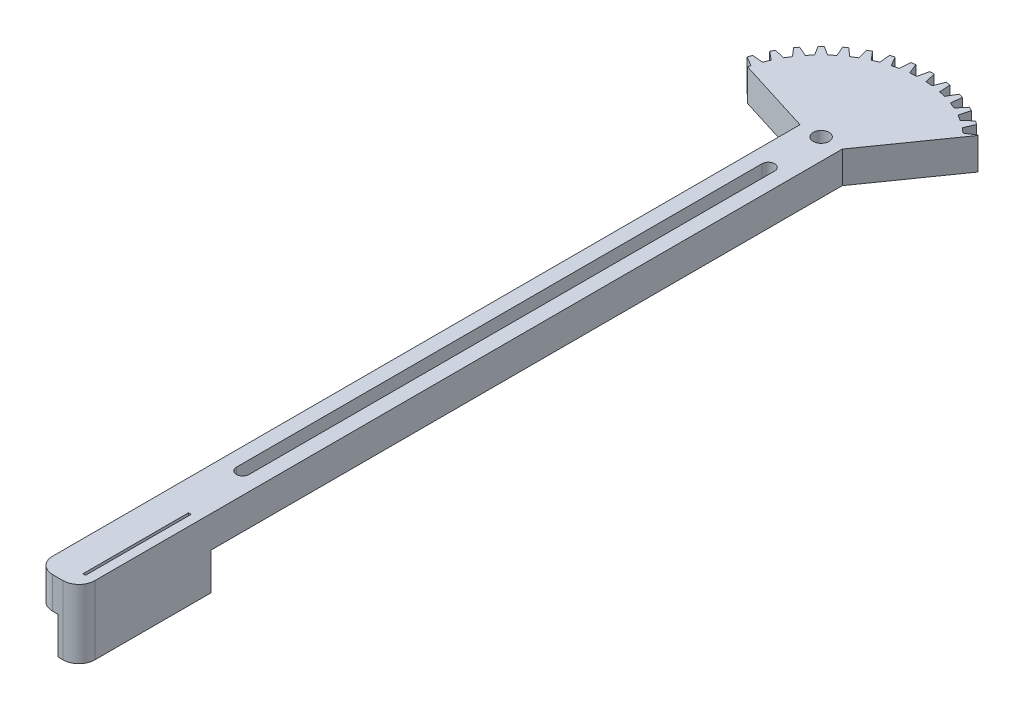
from build123d import *

# Parameters (mm, degrees)
SKETCH1_R           = 21
SKETCH1_R_2         = 1.5
BOSS_EXTRUDE1_DEPTH = 6
CUT_EXTRUDE1_DEPTH  = 6
CIRPATTERN1_COUNT   = 40
CUT_EXTRUDE2_REACH  = 8
BOSS_EXTRUDE2_DEPTH = 6
BOSS_EXTRUDE3_DEPTH = 7
CUT_EXTRUDE4_REACH  = 15
SKETCH7_W           = 0.5
SKETCH7_H           = 20
CUT_EXTRUDE5_REACH  = 8


with BuildPart() as part:
    # Sketch1 → Boss-Extrude1 (new body)
    with BuildSketch(Plane(origin=(0, 0, 0), x_dir=(1, 0, 0), z_dir=(0, 1, 0))):
        Circle(SKETCH1_R)
        Circle(SKETCH1_R_2, mode=Mode.SUBTRACT)
    extrude(amount=BOSS_EXTRUDE1_DEPTH)

    # Sketch2 → Cut-Extrude1 (cut)
    with BuildSketch(Plane(origin=(0, 6, 0), x_dir=(1, 0, 0), z_dir=(0, 1, 0))):
        with BuildLine():
            Line((-0.870178472, 18.980062946), (-0.412307542, 20.99595205))
            ThreePointArc((-0.412307542, 20.99595205), (0, 21), (0.412307542, 20.99595205))
            Line((0.412307542, 20.99595205), (0.870178472, 18.980062946))
            ThreePointArc((0.870178472, 18.980062946), (1.180608684, 18.963284608), (1.490722819, 18.941429341))
            Line((1.490722819, 18.941429341), (1.73143755, 22))
            Line((1.73143755, 22), (-1.73143755, 22))
            Line((-1.73143755, 22), (-1.490722819, 18.941429341))
            ThreePointArc((-1.490722819, 18.941429341), (-1.180608684, 18.963284608), (-0.870178472, 18.980062946))
        make_face()
    cut_extrude1 = extrude(amount=-CUT_EXTRUDE1_DEPTH, mode=Mode.SUBTRACT)

    # CirPattern1: Cut-Extrude1 ×40 about axis
    cirpattern1_axis = Axis((0, 0, 0), (0, 1, 0))
    for i in range(1, CIRPATTERN1_COUNT):
        add(cut_extrude1.rotate(cirpattern1_axis, i * 360 / CIRPATTERN1_COUNT), mode=Mode.SUBTRACT)

    # Sketch3 → Cut-Extrude2 (cut, up to next)
    with BuildSketch(Plane(origin=(0, 6, 0), x_dir=(1, 0, 0), z_dir=(0, 1, 0)), mode=Mode.PRIVATE) as cut_extrude2_sk1:
        with BuildLine():
            Line((-4, 0), (-20.367312321, 5.115915248))
            ThreePointArc((-20.367312321, 5.115915248), (5.753143593, -20.196567501), (14.614168728, 15.080652253))
            Line((14.614168728, 15.080652253), (4, 0))
            Line((4, 0), (-4, 0))
        make_face()
    cut_extrude2_tool1 = extrude(cut_extrude2_sk1.sketch, amount=-CUT_EXTRUDE2_REACH, mode=Mode.PRIVATE) & part.part
    add(cut_extrude2_tool1.solids().sort_by_distance((1.540678, 6, 6.01351))[0], mode=Mode.SUBTRACT)

    # Sketch4 → Boss-Extrude2 (add)
    with BuildSketch(Plane.XZ):
        with BuildLine():
            Line((1.5, 0), (4, 0))
            Line((4, 0), (4, 141.5))
            ThreePointArc((4, 141.5), (3.121320344, 143.621320344), (1, 144.5))
            Line((1, 144.5), (-1, 144.5))
            ThreePointArc((-1, 144.5), (-3.121320344, 143.621320344), (-4, 141.5))
            Line((-4, 141.5), (-4, 0))
            Line((-4, 0), (-1.5, 0))
            ThreePointArc((-1.5, 0), (0, 1.5), (1.5, 0))
        make_face()
    extrude(amount=-BOSS_EXTRUDE2_DEPTH)

    # Sketch5 → Boss-Extrude3 (add)
    with BuildSketch(Plane.XZ):
        with BuildLine():
            Line((0, 144.5), (0, 119.5))
            Line((0, 119.5), (4, 119.5))
            Line((4, 119.5), (4, 141.5))
            ThreePointArc((4, 141.5), (3.121320344, 143.621320344), (1, 144.5))
            Line((1, 144.5), (0, 144.5))
        make_face()
    extrude(amount=BOSS_EXTRUDE3_DEPTH)

    # Sketch7 → Cut-Extrude4 (cut, up to next)
    with BuildSketch(Plane.XZ.offset(7), mode=Mode.PRIVATE) as cut_extrude4_sk1:
        with Locations((2, 131.5)):
            Rectangle(SKETCH7_W, SKETCH7_H)
    cut_extrude4_tool1 = extrude(cut_extrude4_sk1.sketch, amount=-CUT_EXTRUDE4_REACH, mode=Mode.PRIVATE) & part.part
    add(cut_extrude4_tool1.solids().sort_by_distance((2, -7, 131.5))[0], mode=Mode.SUBTRACT)

    # Sketch8 → Cut-Extrude5 (cut, up to next)
    with BuildSketch(Plane.XZ, mode=Mode.PRIVATE) as cut_extrude5_sk1:
        with BuildLine():
            Line((-1.2, 10), (-1.2, 109.5))
            ThreePointArc((-1.2, 109.5), (0, 110.7), (1.2, 109.5))
            Line((1.2, 109.5), (1.2, 10))
            ThreePointArc((1.2, 10), (0, 8.8), (-1.2, 10))
        make_face()
    cut_extrude5_tool1 = extrude(cut_extrude5_sk1.sketch, amount=-CUT_EXTRUDE5_REACH, mode=Mode.PRIVATE) & part.part
    add(cut_extrude5_tool1.solids().sort_by_distance((0, 0, 59.75))[0], mode=Mode.SUBTRACT)


solid = part.part
